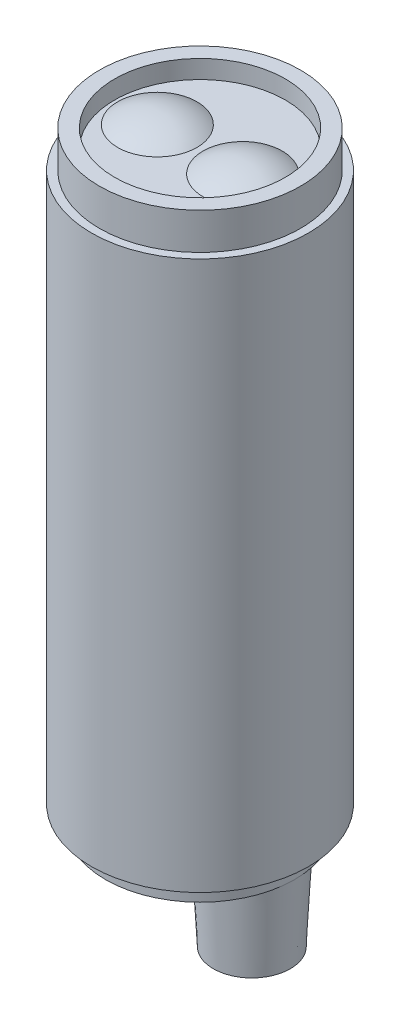
from build123d import *

# Parameters (mm, degrees)
SKETCH1_R           = 8.9
BOSS_EXTRUDE1_DEPTH = 45
SKETCH2_R           = 8.25
SKETCH2_R_2         = 7
BOSS_EXTRUDE2_DEPTH = 3
SKETCH3_R           = 7
BOSS_EXTRUDE3_DEPTH = 1.5
SKETCH6_R           = 7.75
BOSS_EXTRUDE4_DEPTH = 1.5
SKETCH7_R           = 3.5
BOSS_EXTRUDE5_DEPTH = 6.5
BOSS_EXTRUDE5_TAPER = 3


with BuildPart() as part:
    # Sketch1 → Boss-Extrude1 (new body)
    with BuildSketch(Plane(origin=(0, 0, 0), x_dir=(1, 0, 0), z_dir=(0, 1, 0))):
        Circle(SKETCH1_R)
    extrude(amount=BOSS_EXTRUDE1_DEPTH)

    # Sketch2 → Boss-Extrude2 (add)
    with BuildSketch(Plane(origin=(0, 45, 0), x_dir=(1, 0, 0), z_dir=(0, 1, 0))):
        Circle(SKETCH2_R)
        Circle(SKETCH2_R_2, mode=Mode.SUBTRACT)
    extrude(amount=BOSS_EXTRUDE2_DEPTH)

    # Sketch3 → Boss-Extrude3 (add)
    with BuildSketch(Plane(origin=(0, 45, 0), x_dir=(1, 0, 0), z_dir=(0, 1, 0))):
        Circle(SKETCH3_R)
    extrude(amount=BOSS_EXTRUDE3_DEPTH)

    # Sketch5 → Revolve5 (revolve)
    with BuildSketch(Plane.XY):
        with BuildLine():
            Line((-3.5, 46.5), (-3.5, 47.5))
            ThreePointArc((-3.5, 47.5), (-1.799816186, 47.244347394), (-0.25, 46.5))
            Line((-0.25, 46.5), (-3.5, 46.5))
        make_face()
    revolve5 = revolve(axis=Axis((-3.5, 46.5, 0), (0, 1, 0)))

    # Mirror1: Revolve5 across plane
    add(revolve5.mirror(Plane(origin=(0, 0, 0), x_dir=(0, 0, 1), z_dir=(1, 0, 0))))


with BuildPart() as body_2:
    # Sketch6 → Boss-Extrude4 (new body)
    with BuildSketch(Plane.XZ):
        Circle(SKETCH6_R)
    extrude(amount=BOSS_EXTRUDE4_DEPTH)

    # Sketch7 → Boss-Extrude5 (add)
    with BuildSketch(Plane.XZ.offset(1.5)):
        with Locations((4.25, 0)):
            Circle(SKETCH7_R)
    extrude(amount=BOSS_EXTRUDE5_DEPTH, taper=BOSS_EXTRUDE5_TAPER)


solid = Compound([part.part, body_2.part])
